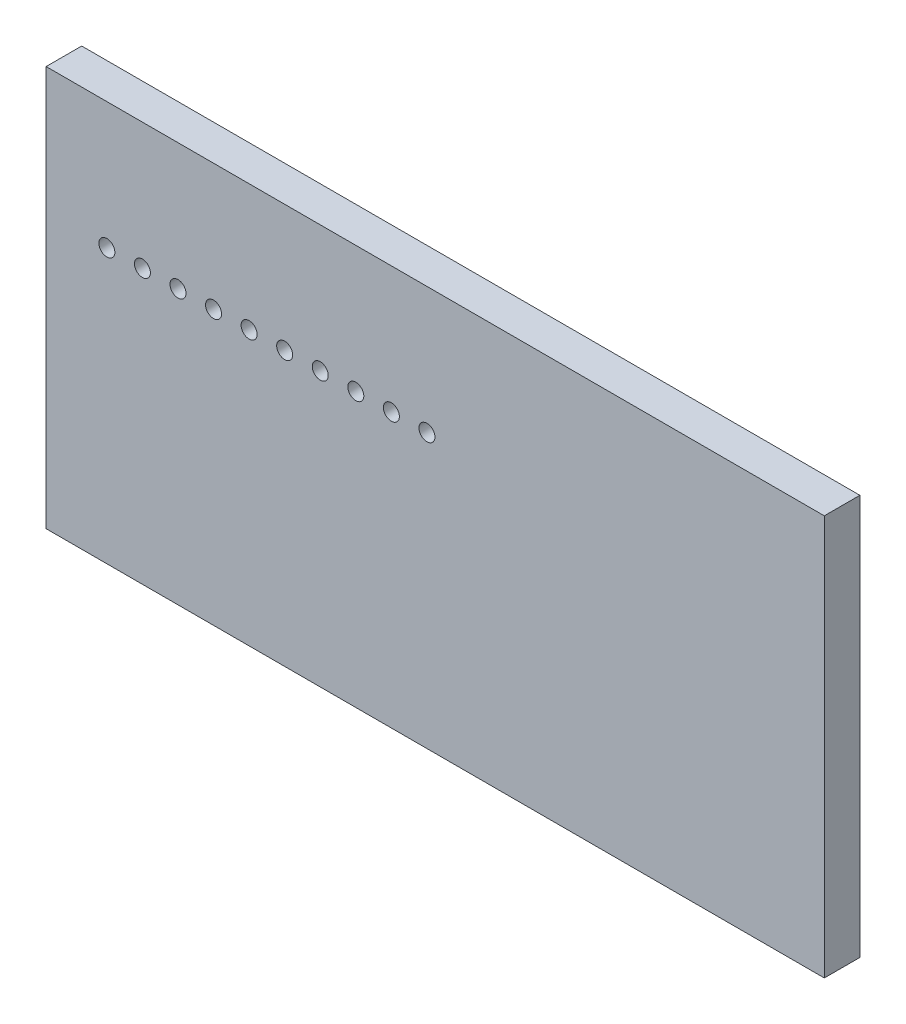
from build123d import *

# Parameters (mm, degrees)
ESQUISSE1_W                = 218.82438545
ESQUISSE1_H                = 112.55663444
BOSS_EXTRU_1_DEPTH         = 10
D_GAGEMENT_M41_D           = 4.5
D_GAGEMENT_M41_DEPTH       = 10
R_P_TITION_LIN_AIRE1_COUNT = 10
R_P_TITION_LIN_AIRE1_PITCH = 10


with BuildPart() as part:
    # Esquisse1 → Boss.-Extru.1 (new body)
    with BuildSketch(Plane.XY):
        Rectangle(ESQUISSE1_W, ESQUISSE1_H)
    extrude(amount=BOSS_EXTRU_1_DEPTH)

    # Dégagement M41
    with Locations(Plane.XY.offset(10)):
        with Locations((-92.332337332, 20.690425989)):
            d_gagement_m41 = Hole(D_GAGEMENT_M41_D / 2, depth=D_GAGEMENT_M41_DEPTH)

    # Répétition linéaire1: Dégagement M41 ×10
    with Locations(*[(i * R_P_TITION_LIN_AIRE1_PITCH, 0, 0) for i in range(1, R_P_TITION_LIN_AIRE1_COUNT)]):
        add(d_gagement_m41, mode=Mode.SUBTRACT)


solid = part.part
